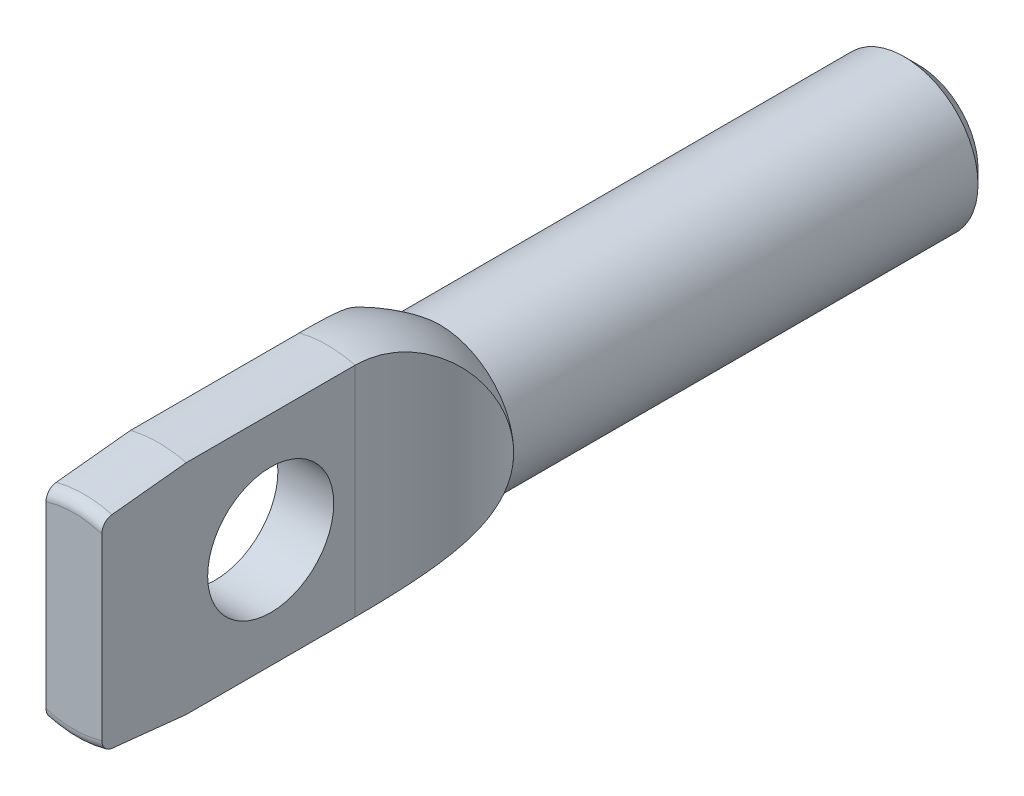
from build123d import *

# Parameters (mm, degrees)
HEAD_CUT_DEPTH      = 20.572014492
HEAD_CUT_DEPTH_BACK = 20.572014492
HOLE_CUT_DEPTH      = 20.424756933
HOLE_CUT_DEPTH_BACK = 20.424756933
SKETCH6_R           = 1.778


with BuildPart() as part:
    # Sketch3 → Body Revolve (revolve)
    with BuildSketch(Plane(origin=(0, 0, 0), x_dir=(0, 0, -1), z_dir=(1, 0, 0))):
        with BuildLine():
            Line((19.05, 0), (19.05, 1.685925))
            Line((19.05, 1.685925), (18.653125, 2.0828))
            Line((18.653125, 2.0828), (5.55625, 2.0828))
            ThreePointArc((5.55625, 2.0828), (4.060634728, 2.894312369), (2.382352325, 3.175))
            Line((2.382352325, 3.175), (-2.38125, 3.175))
            Line((-2.38125, 3.175), (-4.477145765, 2.961701818))
            ThreePointArc((-4.477145765, 2.961701818), (-4.680597677, 2.858671264), (-4.7625, 2.645833333))
            Line((-4.7625, 2.645833333), (-4.7625, 0))
            Line((-4.7625, 0), (19.05, 0))
        make_face()
    revolve(axis=Axis((0, 0, 4.7625), (0, 0, -1)))

    # Sketch5 → Head Cut (cut, two sides: drawn at the far end of the back side and taken through both)
    with BuildSketch(Plane(origin=(0, 0, 0), x_dir=(1, 0, 0), z_dir=(0, 1, 0)).offset(-HEAD_CUT_DEPTH_BACK)):
        with BuildLine():
            Line((-3.9624, 5.55625), (-3.9624, -4.7625))
            Line((-3.9624, -4.7625), (-0.7874, -4.7625))
            Line((-0.7874, -4.7625), (-0.7874, 2.382352325))
            ThreePointArc((-0.7874, 2.382352325), (-1.12371822, 4.096389053), (-2.0828, 5.55625))
            Line((-2.0828, 5.55625), (-3.9624, 5.55625))
        make_face()
        with BuildLine():
            Line((2.0828, 5.55625), (3.9624, 5.55625))
            Line((3.9624, 5.55625), (3.9624, -4.7625))
            Line((3.9624, -4.7625), (0.7874, -4.7625))
            Line((0.7874, -4.7625), (0.7874, 2.382352325))
            ThreePointArc((0.7874, 2.382352325), (1.12371822, 4.096389053), (2.0828, 5.55625))
        make_face()
    extrude(amount=HEAD_CUT_DEPTH + HEAD_CUT_DEPTH_BACK, mode=Mode.SUBTRACT)

    # Sketch6 → Hole Cut (cut, two sides: drawn at the far end of the back side and taken through both)
    with BuildSketch(Plane(origin=(0, 0, 0), x_dir=(0, 0, -1), z_dir=(1, 0, 0)).offset(-HOLE_CUT_DEPTH_BACK)):
        Circle(SKETCH6_R)
    extrude(amount=HOLE_CUT_DEPTH + HOLE_CUT_DEPTH_BACK, mode=Mode.SUBTRACT)


solid = part.part
